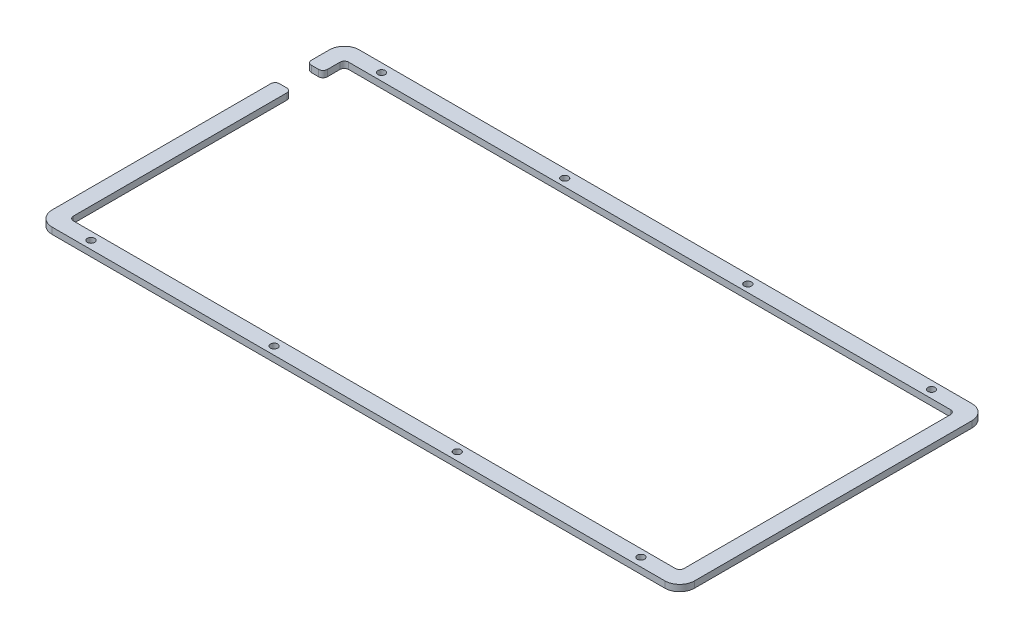
from build123d import *

# Parameters (mm, degrees)
SKETCH1_W           = 350
SKETCH1_H           = 200
BOSS_EXTRUDE1_DEPTH = 3
SKETCH2_OUTSIDE_W   = 432.624
SKETCH2_OUTSIDE_H   = 282.624
SKETCH2_OUTSIDE_R   = 1.7
CUT_EXTRUDE1_DEPTH  = 10


with BuildPart() as part:
    # Sketch1 → Boss-Extrude1 (new body)
    with BuildSketch(Plane(origin=(0, 0, 0), x_dir=(1, 0, 0), z_dir=(0, 1, 0))):
        with Locations((175, 100)):
            Rectangle(SKETCH1_W, SKETCH1_H)
    extrude(amount=BOSS_EXTRUDE1_DEPTH)

    # Sketch2 outside → Cut-Extrude1 (cut)
    with BuildSketch(Plane(origin=(0, 3, 0), x_dir=(1, 0, 0), z_dir=(0, 1, 0))):
        with Locations((175, 100)):
            Rectangle(SKETCH2_OUTSIDE_W, SKETCH2_OUTSIDE_H)
        with BuildLine():
            Line((334.453835379, 22.4974157), (46.754485379, 22.4974157))
            ThreePointArc((46.754485379, 22.4974157), (41.80473791, 24.547668232), (39.754485379, 29.4974157))
            Line((39.754485379, 29.4974157), (39.754485379, 132.1968757))
            ThreePointArc((39.754485379, 132.1968757), (40.340271816, 133.611089262), (41.754485379, 134.1968757))
            Line((41.754485379, 134.1968757), (45.254485379, 134.1968757))
            ThreePointArc((45.254485379, 134.1968757), (46.668698941, 133.611089262), (47.254485379, 132.1968757))
            Line((47.254485379, 132.1968757), (47.254485379, 31.9974157))
            ThreePointArc((47.254485379, 31.9974157), (47.840271816, 30.583202138), (49.254485379, 29.9974157))
            Line((49.254485379, 29.9974157), (331.953835379, 29.9974157))
            ThreePointArc((331.953835379, 29.9974157), (333.368048941, 30.583202138), (333.953835379, 31.9974157))
            Line((333.953835379, 31.9974157), (333.953835379, 157.1968757))
            ThreePointArc((333.953835379, 157.1968757), (333.368048941, 158.611089262), (331.953835379, 159.1968757))
            Line((331.953835379, 159.1968757), (49.254485379, 159.1968757))
            ThreePointArc((49.254485379, 159.1968757), (47.840271816, 158.611089262), (47.254485379, 157.1968757))
            Line((47.254485379, 157.1968757), (47.254485379, 151.1968757))
            ThreePointArc((47.254485379, 151.1968757), (46.668698941, 149.782662138), (45.254485379, 149.1968757))
            Line((45.254485379, 149.1968757), (41.754485379, 149.1968757))
            ThreePointArc((41.754485379, 149.1968757), (40.340271816, 149.782662138), (39.754485379, 151.1968757))
            Line((39.754485379, 151.1968757), (39.754485379, 159.6968757))
            ThreePointArc((39.754485379, 159.6968757), (41.80473791, 164.646623168), (46.754485379, 166.6968757))
            Line((46.754485379, 166.6968757), (334.453835379, 166.6968757))
            ThreePointArc((334.453835379, 166.6968757), (339.403582847, 164.646623168), (341.453835379, 159.6968757))
            Line((341.453835379, 159.6968757), (341.453835379, 29.4974157))
            ThreePointArc((341.453835379, 29.4974157), (339.403582847, 24.547668232), (334.453835379, 22.4974157))
        make_face(mode=Mode.SUBTRACT)
        with Locations((319.254485379, 26.4974157)):
            Circle(SKETCH2_OUTSIDE_R)
        with Locations((233.254485379, 26.2474157)):
            Circle(SKETCH2_OUTSIDE_R)
        with Locations((61.254485379, 26.2474157)):
            Circle(SKETCH2_OUTSIDE_R)
        with Locations((147.254485379, 26.2474157)):
            Circle(SKETCH2_OUTSIDE_R)
        with Locations((319.254485379, 162.9468757)):
            Circle(SKETCH2_OUTSIDE_R)
        with Locations((233.254485379, 162.6968757)):
            Circle(SKETCH2_OUTSIDE_R)
        with Locations((61.254485379, 162.6968757)):
            Circle(SKETCH2_OUTSIDE_R)
        with Locations((147.254485379, 162.6968757)):
            Circle(SKETCH2_OUTSIDE_R)
    extrude(amount=-CUT_EXTRUDE1_DEPTH, mode=Mode.SUBTRACT)


solid = part.part
